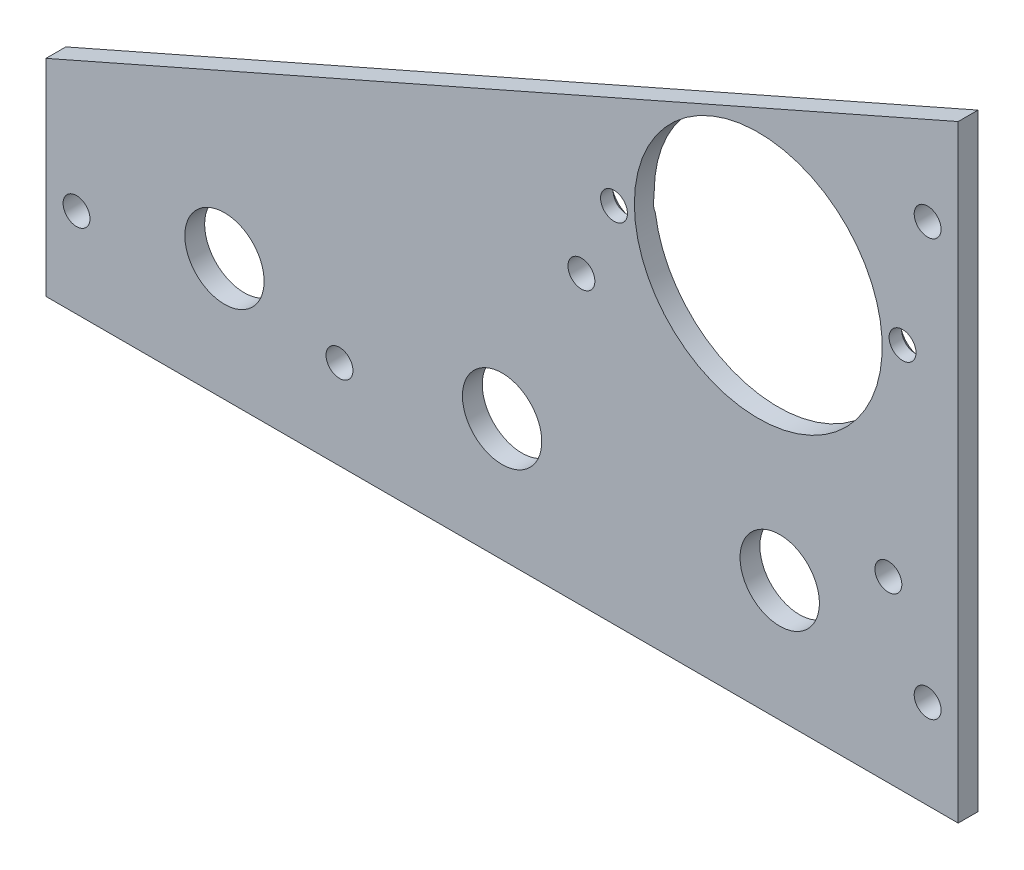
from build123d import *

# Parameters (mm, degrees)
BOSS_EXTRUDE1_DEPTH                               = 3.175
F_6_CLEARANCE_HOLE1_D                             = 4.3053
SKETCH7_R                                         = 19.84375
SKETCH7_R_2                                       = 6.35
CUT_EXTRUDE1_DEPTH                                = 4.175
CSK_FOR_6_FLAT_HEAD_MACHINE_SCREW_100_D           = 4.3053
CSK_FOR_6_FLAT_HEAD_MACHINE_SCREW_100_DEPTH       = 3.175
CSK_FOR_6_FLAT_HEAD_MACHINE_SCREW_100_CSINK_D     = 7.0866
CSK_FOR_6_FLAT_HEAD_MACHINE_SCREW_100_CSINK_ANGLE = 100


with BuildPart() as part:
    # Sketch1 → Boss-Extrude1 (new body)
    with BuildSketch(Plane.XY):
        Polygon((0, 97.282), (-146.05, 33.02), (-146.05, 0), (0, 0), align=None)
    extrude(amount=-BOSS_EXTRUDE1_DEPTH)

    # #6 Clearance Hole1 (through all)
    with Locations(Plane(origin=(0, 0, -3.175), x_dir=(-1, 0, 0), z_dir=(0, 0, -1))):
        with Locations((4.8895, 80.9625), (4.8895, 14.2875), (141.1605, 14.2875), (11.176, 28.575), (60.325, 46.0375), (99.06, 14.2875)):
            Hole(F_6_CLEARANCE_HOLE1_D / 2)

    # Sketch7 → Cut-Extrude1 (cut, through all)
    with BuildSketch(Plane(origin=(0, 0, -3.175), x_dir=(-1, 0, 0), z_dir=(0, 0, -1))):
        with Locations((32.004, 59.944)):
            Circle(SKETCH7_R)
        with Locations((28.575, 19.375884027)):
            Circle(SKETCH7_R_2)
        with Locations((73.025, 19.558)):
            Circle(SKETCH7_R_2)
        with Locations((117.475, 19.558)):
            Circle(SKETCH7_R_2)
    extrude(amount=-CUT_EXTRUDE1_DEPTH, mode=Mode.SUBTRACT)

    # CSK for #6 Flat Head Machine Screw (100)1
    with Locations(Plane(origin=(0, 0, -3.175), x_dir=(-1, 0, 0), z_dir=(0, 0, -1))):
        with Locations((8.904042987, 61.838331605), (55.103957013, 58.049668395)):
            CounterSinkHole(CSK_FOR_6_FLAT_HEAD_MACHINE_SCREW_100_D / 2, CSK_FOR_6_FLAT_HEAD_MACHINE_SCREW_100_CSINK_D / 2, depth=CSK_FOR_6_FLAT_HEAD_MACHINE_SCREW_100_DEPTH, counter_sink_angle=CSK_FOR_6_FLAT_HEAD_MACHINE_SCREW_100_CSINK_ANGLE)


solid = part.part
